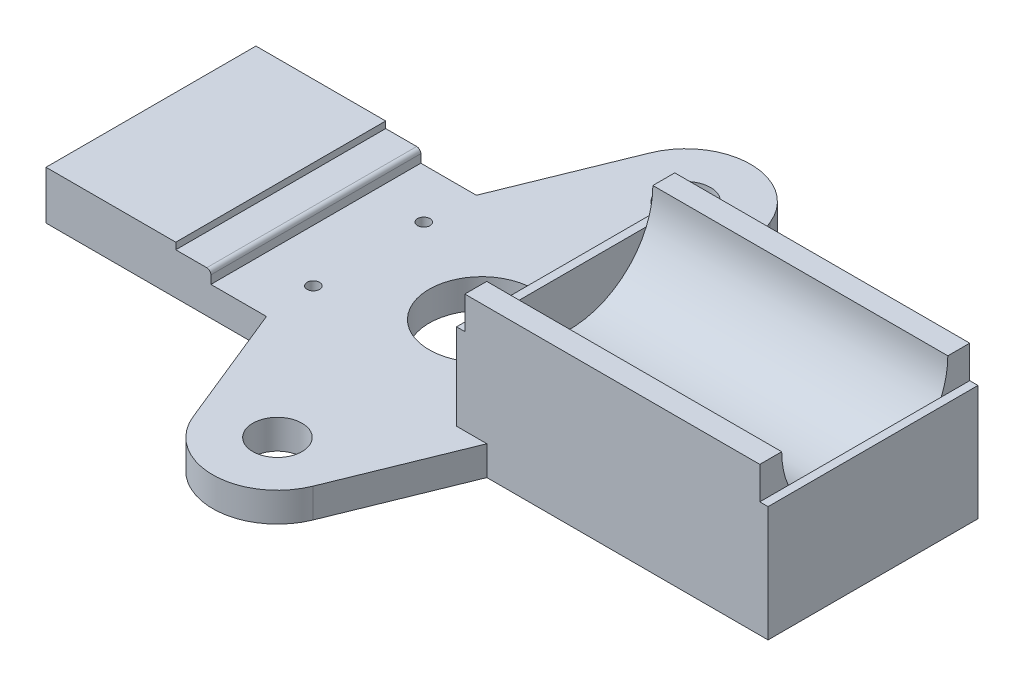
from build123d import *

# Parameters (mm, degrees)
SKETCH1_W           = 172.72
SKETCH1_H           = 50.8
BOSS_EXTRUDE1_DEPTH = 12.7
BOSS_EXTRUDE2_DEPTH = 71.374
SKETCH5_W           = 50.8
SKETCH5_H           = 27.94
BOSS_EXTRUDE3_DEPTH = 2
SKETCH6_W           = 50.8
SKETCH6_H           = 15.24
BOSS_EXTRUDE4_DEPTH = 2
CUT_EXTRUDE1_DEPTH  = 51.8
FILLET1_R           = 1
SKETCH8_R           = 12.7
CUT_EXTRUDE2_DEPTH  = 7.1
SKETCH9_R           = 5.9563
BOSS_EXTRUDE5_DEPTH = 7.1
SKETCH10_R          = 1.5
CUT_EXTRUDE3_DEPTH  = 7.1


with BuildPart() as part:
    # Sketch1 → Boss-Extrude1 (new body)
    with BuildSketch(Plane(origin=(0, 0, 0), x_dir=(1, 0, 0), z_dir=(0, 1, 0))):
        Rectangle(SKETCH1_W, SKETCH1_H)
    extrude(amount=BOSS_EXTRUDE1_DEPTH)

    # Sketch4 → Boss-Extrude2 (add)
    with BuildSketch(Plane(origin=(86.36, 0, 0), x_dir=(0, 0, -1), z_dir=(1, 0, 0))):
        with BuildLine():
            Line((-25.4, 12.7), (-25.4, 35.8))
            Line((-25.4, 35.8), (-20.1, 35.8))
            ThreePointArc((-20.1, 35.8), (0, 15.7), (20.1, 35.8))
            Line((20.1, 35.8), (25.4, 35.8))
            Line((25.4, 35.8), (25.4, 12.7))
            Line((25.4, 12.7), (-25.4, 12.7))
        make_face()
    extrude(amount=-BOSS_EXTRUDE2_DEPTH)

    # Sketch5 → Boss-Extrude3 (add)
    with BuildSketch(Plane(origin=(86.36, 0, 0), x_dir=(0, 0, -1), z_dir=(1, 0, 0))):
        with Locations((0, 13.97)):
            Rectangle(SKETCH5_W, SKETCH5_H)
    extrude(amount=BOSS_EXTRUDE3_DEPTH)

    # Sketch6 → Boss-Extrude4 (add)
    with BuildSketch(Plane.ZY.offset(-14.986)):
        with Locations((0, 20.32)):
            Rectangle(SKETCH6_W, SKETCH6_H)
    extrude(amount=BOSS_EXTRUDE4_DEPTH)

    # Sketch7 → Cut-Extrude1 (cut, through all)
    with BuildSketch(Plane.XY.offset(25.4)):
        Polygon((-86.36, 12.7), (-86.36, 11.7), (-54.96, 11.7), (-54.96, 10.1), (-46.45999982, 10.1), (-46.45999982, 7.1), (12.986, 7.1), (12.986, 12.7), align=None)
    extrude(amount=-CUT_EXTRUDE1_DEPTH, mode=Mode.SUBTRACT)

    # Fillet1
    fillet1_edges = [part.edges().sort_by_distance(p)[0] for p in [
        (-46.45999982, 10.1, 0),
    ]]
    fillet(fillet1_edges, radius=FILLET1_R)

    # Sketch8 → Cut-Extrude2 (cut)
    with BuildSketch(Plane.XZ):
        with Locations((-6.35, 0)):
            Circle(SKETCH8_R)
    extrude(amount=-CUT_EXTRUDE2_DEPTH, mode=Mode.SUBTRACT)

    # Sketch9 → Boss-Extrude5 (add)
    with BuildSketch(Plane(origin=(0, 0, 0), x_dir=(1, 0, 0), z_dir=(0, 1, 0))):
        with BuildLine():
            Line((-33.02, 25.4), (-20.875030517, 55.308759963))
            ThreePointArc((-20.875030517, 55.308759963), (-6.35, 65.0875), (8.175030517, 55.308759963))
            Line((8.175030517, 55.308759963), (20.32, 25.4))
            Line((20.32, 25.4), (-33.02, 25.4))
        make_face()
        with Locations((-6.35, 49.41062)):
            Circle(SKETCH9_R, mode=Mode.SUBTRACT)
        with BuildLine():
            Line((20.32, -25.4), (-33.02, -25.4))
            Line((-33.02, -25.4), (-20.875030517, -55.308759963))
            ThreePointArc((-20.875030517, -55.308759963), (-6.35, -65.0875), (8.175030517, -55.308759963))
            Line((8.175030517, -55.308759963), (20.32, -25.4))
        make_face()
        with Locations((-6.35, -49.41062)):
            Circle(SKETCH9_R, mode=Mode.SUBTRACT)
    extrude(amount=BOSS_EXTRUDE5_DEPTH)

    # Sketch10 → Cut-Extrude3 (cut)
    with BuildSketch(Plane(origin=(0, 7.1, 0), x_dir=(1, 0, 0), z_dir=(0, 1, 0))):
        with Locations((-33.75999982, 13.41)):
            Circle(SKETCH10_R)
        with Locations((-33.75999982, -13.31)):
            Circle(SKETCH10_R)
    extrude(amount=-CUT_EXTRUDE3_DEPTH, mode=Mode.SUBTRACT)


solid = part.part
